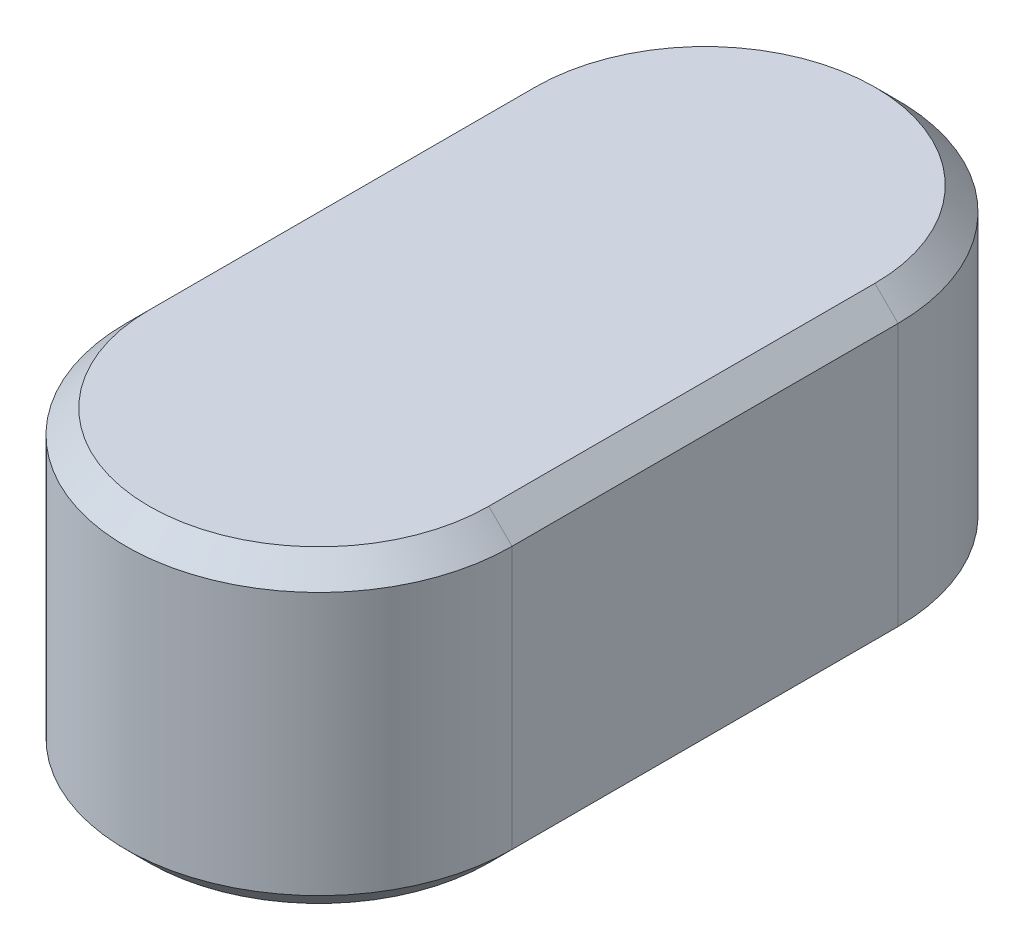
from build123d import *

# Parameters (mm, degrees)
BOSS_EXTRUDE1_DEPTH = 8
CHAMFER1_SIZE       = 0.6


with BuildPart() as part:
    # Sketch1 → Boss-Extrude1 (new body)
    with BuildSketch(Plane(origin=(0, 0, 0), x_dir=(1, 0, 0), z_dir=(0, 1, 0))):
        with BuildLine():
            Line((5, 0), (5, 10))
            ThreePointArc((5, 10), (0, 15), (-5, 10))
            Line((-5, 10), (-5, 0))
            ThreePointArc((-5, 0), (0, -5), (5, 0))
        make_face()
    extrude(amount=BOSS_EXTRUDE1_DEPTH)

    # Chamfer1
    chamfer1_edges = [part.edges().sort_by_distance(p)[0] for p in [
        (0, 8, -15),
        (-5, 8, -5),
        (0, 8, 5),
        (-5, 0, -5),
        (0, 0, -15),
        (5, 0, -5),
        (0, 0, 5),
        (5, 8, -5),
    ]]
    chamfer(chamfer1_edges, length=CHAMFER1_SIZE)


solid = part.part
